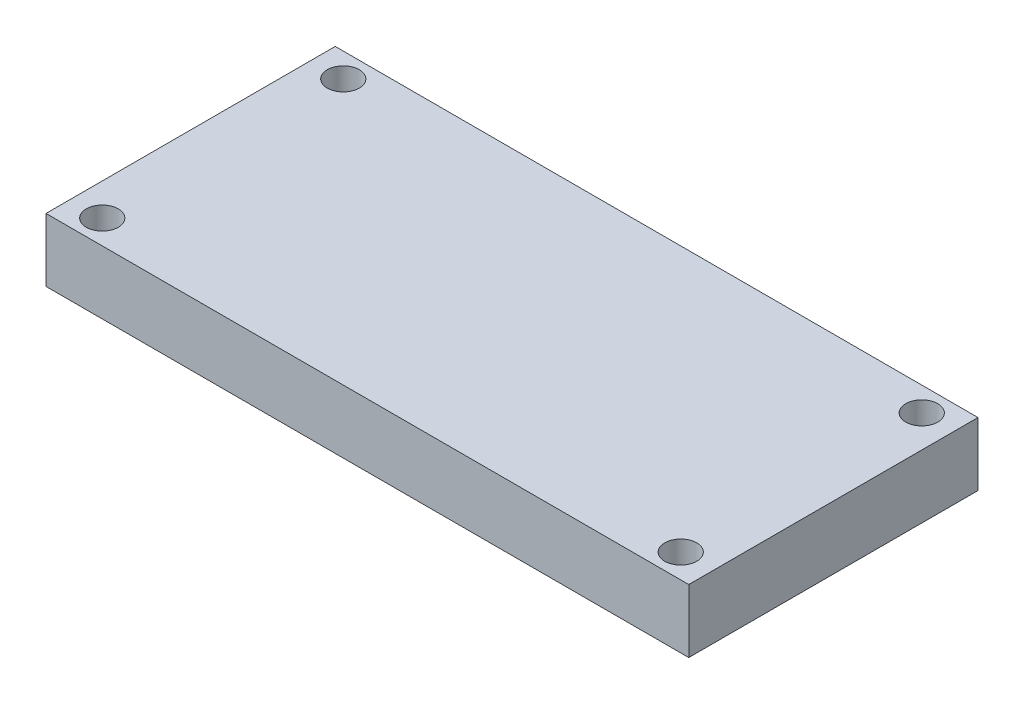
from build123d import *

# Parameters (mm, degrees)
SKETCH1_W                    = 50.8
SKETCH1_H                    = 22.86
BOSS_EXTRUDE1_DEPTH          = 5
F_39_0_0995_DIAMETER_HOLE1_D = 2.5273


with BuildPart() as part:
    # Sketch1 → Boss-Extrude1 (new body)
    with BuildSketch(Plane(origin=(0, 0, 0), x_dir=(1, 0, 0), z_dir=(0, 1, 0))):
        Rectangle(SKETCH1_W, SKETCH1_H)
    extrude(amount=BOSS_EXTRUDE1_DEPTH)

    # 39 _0.0995_ Diameter Hole1 (through all)
    with Locations(Plane(origin=(0, 5, 0), x_dir=(1, 0, 0), z_dir=(0, 1, 0))):
        with Locations((-22.86, 9.525), (-22.86, -9.525), (22.86, 9.525), (22.86, -9.525)):
            Hole(F_39_0_0995_DIAMETER_HOLE1_D / 2)


solid = part.part
